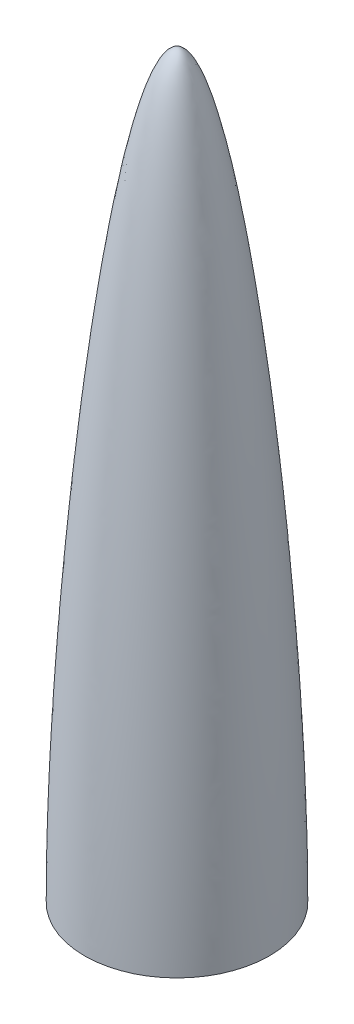
from build123d import *


with BuildPart() as part:
    # Sketch1 → Revolve1 (revolve)
    with BuildSketch(Plane.XY):
        with BuildLine():
            Line((0, 403.069458147), (0, 412.75))
            add(Edge.make_bspline(
                [(0, 412.75), (25.4, 412.75), (51.59375, 152.4), (51.59375, 0)],
                knots=[0, 0, 0, 0, 1, 1, 1, 1], degree=3))
            Line((51.59375, 0), (47.459925842, 0))
            Line((47.459925842, 0), (47.459925842, 4.1275))
            add(Edge.make_bspline(
                [(4.1275, 403.069458147), (4.292023637, 402.747413471), (4.605634702, 402.113699513), (5.259029357, 400.714319487), (6.080525572, 398.802814151), (7.080127661, 396.235904149), (8.420819663, 392.4721057), (10.105321711, 387.147151323), (12.123502842, 379.832445691), (14.128845289, 371.65121683), (16.776022866, 359.660430734), (20.020870541, 342.773209039), (23.775606957, 319.872013846), (27.359943181, 294.724294429), (30.744231406, 267.715477189), (33.899718669, 239.22837658), (36.798067521, 209.644450359), (39.411177746, 179.344383779), (41.711086588, 148.708460893), (43.669922699, 118.116805641), (44.994890425, 92.977467608), (45.856563157, 73.268425899), (46.400209896, 58.735532221), (46.837798789, 44.498916895), (47.111204808, 32.922539677), (47.273470952, 23.856006914), (47.366500737, 17.163999749), (47.430492642, 10.567060356), (47.453369816, 6.283580592), (47.459925842, 4.1275)],
                knots=[0.102456086, 0.102456086, 0.102456086, 0.102456086, 0.109397848, 0.116339609, 0.130223132, 0.144106655, 0.157990177, 0.185757223, 0.213524268, 0.241291314, 0.269058359, 0.32459245, 0.380126541, 0.435660631, 0.491194722, 0.546728813, 0.602262904, 0.657796995, 0.713331086, 0.768865177, 0.824399267, 0.852166313, 0.879933358, 0.907700404, 0.935467449, 0.949350972, 0.963234494, 0.977118017, 0.99100154, 0.99100154, 0.99100154, 0.99100154], degree=3))
            Line((4.1275, 403.069458147), (0, 403.069458147))
        make_face()
    revolve(axis=Axis((0, 433.3875, 0), (0, -1, 0)))


solid = part.part
